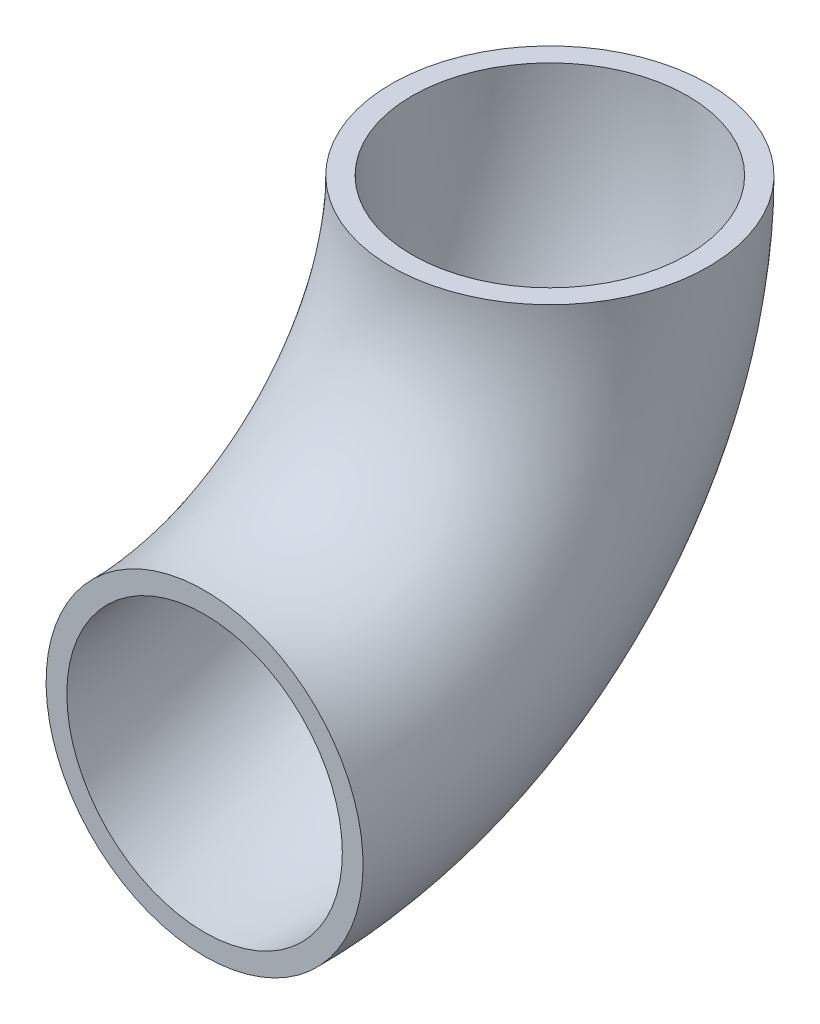
from build123d import *

# Parameters (mm, degrees)
SKETCH1_R      = 44.45
SKETCH1_R_2    = 38.6334
REVOLVE1_ANGLE = 90


with BuildPart() as part:
    # Sketch1 → Revolve1 (revolve)
    with BuildSketch(Plane.XY):
        Circle(SKETCH1_R)
        Circle(SKETCH1_R_2, mode=Mode.SUBTRACT)
    revolve(axis=Axis((-75.138171246, 96.8375, 0), (1, 0, 0)), revolution_arc=REVOLVE1_ANGLE)


solid = part.part
